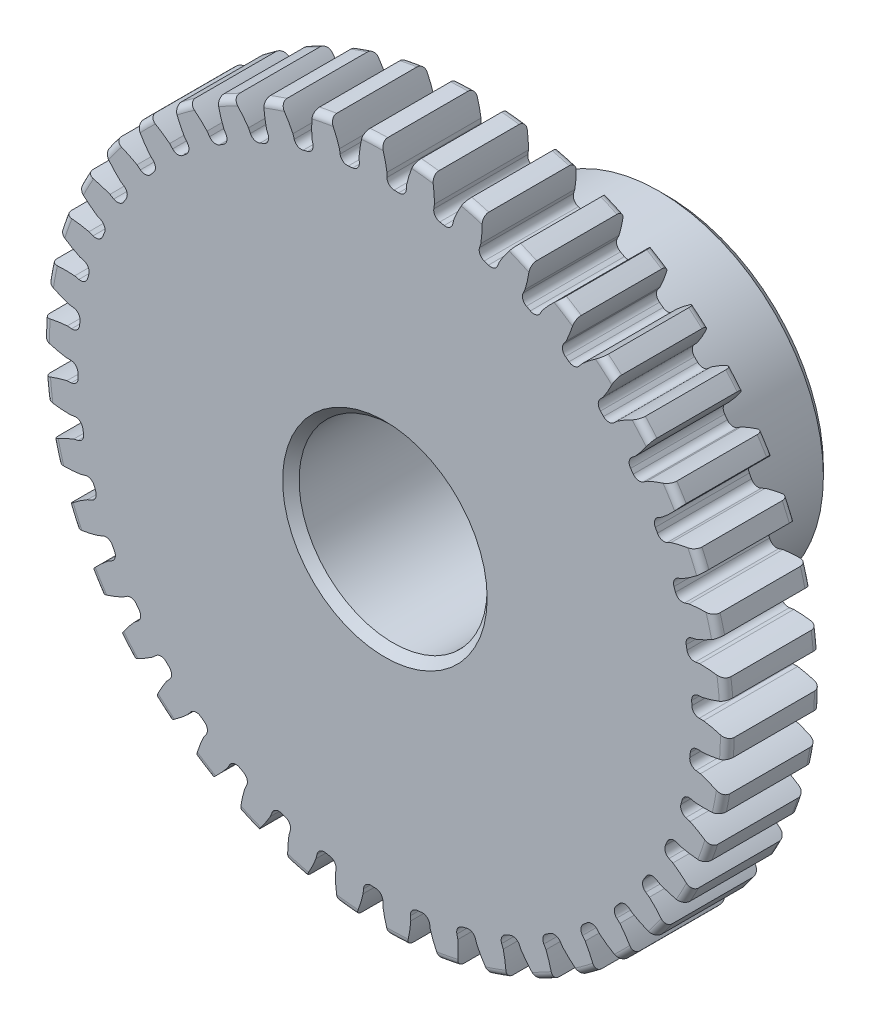
from build123d import *

# Parameters (mm, degrees)
SKETCH1_R                = 11.557
BOSS_EXTRUDE1_DEPTH      = 3.175
SKETCH2_W                = 6.35
SKETCH2_H                = 5.55625
FILLET2_R                = 0.23114
CUT_EXTRUDE1_DEPTH       = 10.525
FILLET1_R                = 0.2493645
CIRPATTERN1_COUNT        = 42
FILLET1_OF_CIRPATTERN1_R = 0.2493645
SKETCH5_R                = 3.175
CUT_EXTRUDE2_DEPTH       = 10.525
CHAMFER1_SIZE            = 0.2778125


with BuildPart() as part:
    # Sketch1 → Boss-Extrude1 (new body)
    with BuildSketch(Plane.XY):
        Circle(SKETCH1_R)
    extrude(amount=-BOSS_EXTRUDE1_DEPTH)

    # Sketch2 → Revolve1 (revolve)
    with BuildSketch(Plane(origin=(0, 0, 0), x_dir=(0, 0, -1), z_dir=(1, 0, 0))):
        with Locations((6.35, 2.778125)):
            Rectangle(SKETCH2_W, SKETCH2_H)
    revolve(axis=Axis((0, 0, -3.175), (0, 0, -1)))

    # Fillet2
    fillet2_edges = [part.edges().sort_by_distance(p)[0] for p in [
        (-11.557, 0, 0),
        (-11.557, 0, -3.175),
        (0, -5.55625, -3.175),
    ]]
    fillet(fillet2_edges, radius=FILLET2_R)

    # Sketch4 → Cut-Extrude1 (cut, through all)
    with BuildSketch(Plane.XY):
        with BuildLine():
            Line((0.069806327, 10.758314184), (0.069806327, 10.366139962))
            ThreePointArc((0.069806327, 10.366139962), (0.387612048, 10.35912581), (0.705053284, 10.342370643))
            Line((0.705053284, 10.342370643), (0.734360569, 10.73344826))
            add(Edge.make_bspline(
                [(2.082393199, 12.940791778), (1.024987107, 12.003022413), (0.734360569, 10.73344826)],
                knots=[0, 0, 0, 1, 1, 1], degree=2))
            ThreePointArc((2.082393199, 12.940791778), (0.49009752, 13.098101302), (-1.10950154, 13.060224333))
            add(Edge.make_bspline(
                [(-1.10950154, 13.060224333), (-0.125131939, 12.046056933), (0.069806327, 10.758314184)],
                knots=[0, 0, 0, 1, 1, 1], degree=2))
        make_face()
    cut_extrude1 = extrude(amount=-CUT_EXTRUDE1_DEPTH, mode=Mode.SUBTRACT)

    # Fillet1
    fillet1_edges = [part.edges().sort_by_distance(p)[0] for p in [
        (0.705053284, 10.342370643, -1.5875),
        (0.069806327, 10.366139962, -1.5875),
    ]]
    fillet(fillet1_edges, radius=FILLET1_R)

    # CirPattern1: Cut-Extrude1 ×42 about axis
    cirpattern1_axis = Axis((0, 0, -3.175), (0, 0, 1))
    for i in range(1, CIRPATTERN1_COUNT):
        add(cut_extrude1.rotate(cirpattern1_axis, i * 360 / CIRPATTERN1_COUNT), mode=Mode.SUBTRACT)

    # Fillet1 of CirPattern1
    fillet1_of_cirpattern1_edges = [part.edges().sort_by_distance(p)[0] for p in [
        (-0.844271937, 10.331937647, -1.5875),
        (-1.475966343, 10.260762837, -1.5875),
        (-2.374737518, 10.090706237, -1.5875),
        (-2.988768365, 9.926177225, -1.5875),
        (-3.852155387, 9.624065124, -1.5875),
        (-4.434806239, 9.369857217, -1.5875),
        (-5.24352247, 8.9424383, -1.5875),
        (-5.781777871, 8.604230081, -1.5875),
        (-6.517757925, 8.061052181, -1.5875),
        (-6.999594139, 7.646398664, -1.5875),
        (-7.646397439, 6.999595477, -1.5875),
        (-8.061051041, 6.517759335, -1.5875),
        (-8.60422907, 5.781779376, -1.5875),
        (-8.942437383, 5.243524034, -1.5875),
        (-9.369856441, 4.434807878, -1.5875),
        (-9.624064451, 3.85215707, -1.5875),
        (-9.926176702, 2.988770101, -1.5875),
        (-10.090705822, 2.374739283, -1.5875),
        (-10.260762579, 1.475968138, -1.5875),
        (-10.331937499, 0.844273744, -1.5875),
        (-10.366139974, -0.069804514, -1.5875),
        (-10.342370766, -0.705051475, -1.5875),
        (-10.239954933, -1.614017849, -1.5875),
        (-10.12177256, -2.238627009, -1.5875),
        (-9.885026219, -3.122176691, -1.5875),
        (-9.675070681, -3.722195315, -1.5875),
        (-9.309282354, -4.560591266, -1.5875),
        (-9.01224371, -5.122615928, -1.5875),
        (-8.525584504, -5.897129768, -1.5875),
        (-8.148098107, -6.408605767, -1.5875),
        (-7.551439185, -7.101936136, -1.5875),
        (-7.101937457, -7.551437942, -1.5875),
        (-6.408607192, -8.148096986, -1.5875),
        (-5.89713126, -8.525583472, -1.5875),
        (-5.122617505, -9.012242814, -1.5875),
        (-4.560592895, -9.309281556, -1.5875),
        (-3.722197007, -9.67507003, -1.5875),
        (-3.122178421, -9.885025673, -1.5875),
        (-2.238628779, -10.121772168, -1.5875),
        (-1.61401964, -10.23995465, -1.5875),
        (-0.705053284, -10.342370643, -1.5875),
        (-0.069806327, -10.366139962, -1.5875),
        (0.844271937, -10.331937647, -1.5875),
        (1.475966343, -10.260762837, -1.5875),
        (2.374737518, -10.090706237, -1.5875),
        (2.988768365, -9.926177225, -1.5875),
        (3.852155387, -9.624065124, -1.5875),
        (4.434806239, -9.369857217, -1.5875),
        (5.24352247, -8.9424383, -1.5875),
        (5.781777871, -8.604230081, -1.5875),
        (6.517757925, -8.061052181, -1.5875),
        (6.999594139, -7.646398664, -1.5875),
        (7.646397439, -6.999595477, -1.5875),
        (8.061051041, -6.517759335, -1.5875),
        (8.60422907, -5.781779376, -1.5875),
        (8.942437383, -5.243524034, -1.5875),
        (9.369856441, -4.434807878, -1.5875),
        (9.624064451, -3.85215707, -1.5875),
        (9.926176702, -2.988770101, -1.5875),
        (10.090705822, -2.374739283, -1.5875),
        (10.260762579, -1.475968138, -1.5875),
        (10.331937499, -0.844273744, -1.5875),
        (10.366139974, 0.069804514, -1.5875),
        (10.342370766, 0.705051475, -1.5875),
        (10.239954933, 1.614017849, -1.5875),
        (10.12177256, 2.238627009, -1.5875),
        (9.885026219, 3.122176691, -1.5875),
        (9.675070681, 3.722195315, -1.5875),
        (9.309282354, 4.560591266, -1.5875),
        (9.01224371, 5.122615928, -1.5875),
        (8.525584504, 5.897129768, -1.5875),
        (8.148098107, 6.408605767, -1.5875),
        (7.551439185, 7.101936136, -1.5875),
        (7.101937457, 7.551437942, -1.5875),
        (6.408607192, 8.148096986, -1.5875),
        (5.89713126, 8.525583472, -1.5875),
        (5.122617505, 9.012242814, -1.5875),
        (4.560592895, 9.309281556, -1.5875),
        (3.722197007, 9.67507003, -1.5875),
        (3.122178421, 9.885025673, -1.5875),
        (2.238628779, 10.121772168, -1.5875),
        (1.61401964, 10.23995465, -1.5875),
    ]]
    fillet(fillet1_of_cirpattern1_edges, radius=FILLET1_OF_CIRPATTERN1_R)

    # Sketch5 → Cut-Extrude2 (cut, through all)
    with BuildSketch(Plane.XY):
        Circle(SKETCH5_R)
    extrude(amount=-CUT_EXTRUDE2_DEPTH, mode=Mode.SUBTRACT)

    # Chamfer1
    chamfer1_edges = [part.edges().sort_by_distance(p)[0] for p in [
        (-3.175, 0, -9.525),
        (-3.175, 0, 0),
        (0, -5.55625, -9.525),
    ]]
    chamfer(chamfer1_edges, length=CHAMFER1_SIZE)


solid = part.part
